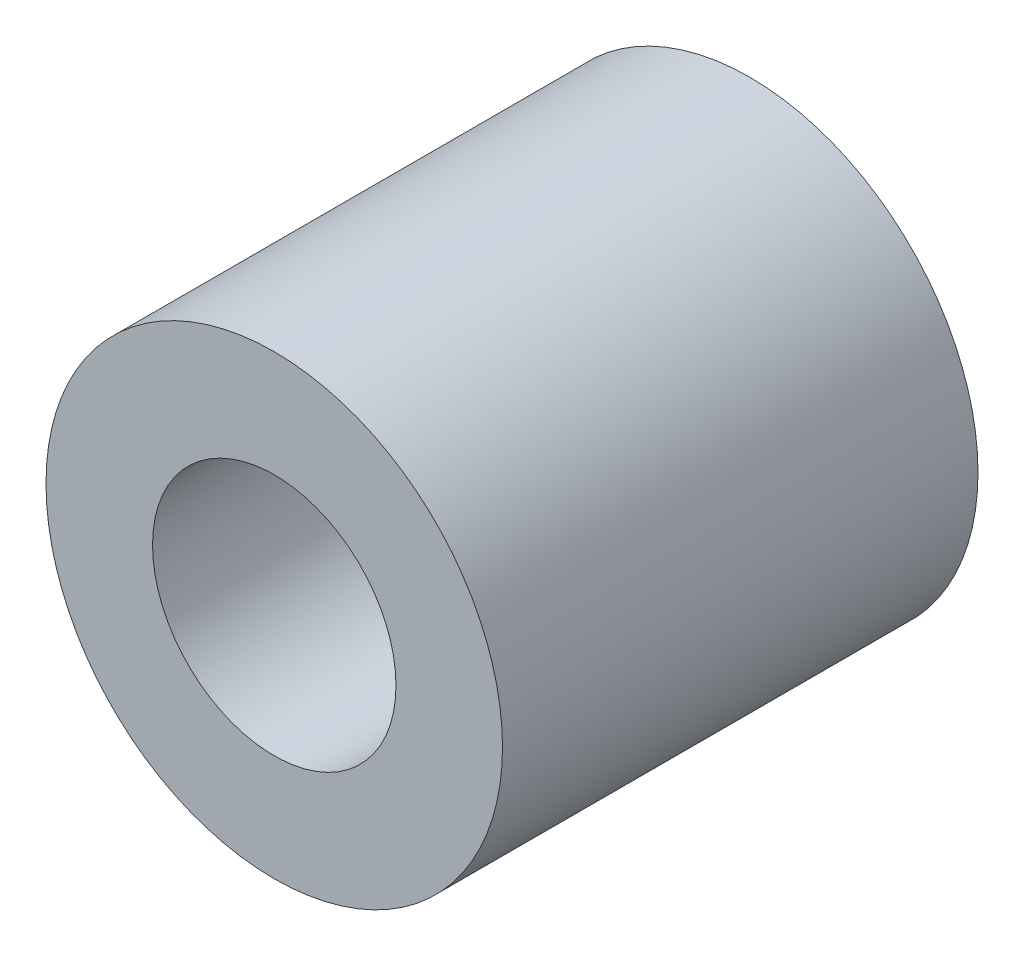
from build123d import *

# Parameters (mm, degrees)
SKETCH_1_R      = 3
SKETCH_1_R_2    = 1.6
EXTRUDE_1_DEPTH = 6.25


with BuildPart() as part:
    # ｽｹｯﾁ1 → ﾎﾞｽ - 押し出し1 (new body)
    with BuildSketch(Plane.XY):
        Circle(SKETCH_1_R)
        Circle(SKETCH_1_R_2, mode=Mode.SUBTRACT)
    extrude(amount=EXTRUDE_1_DEPTH)


solid = part.part
